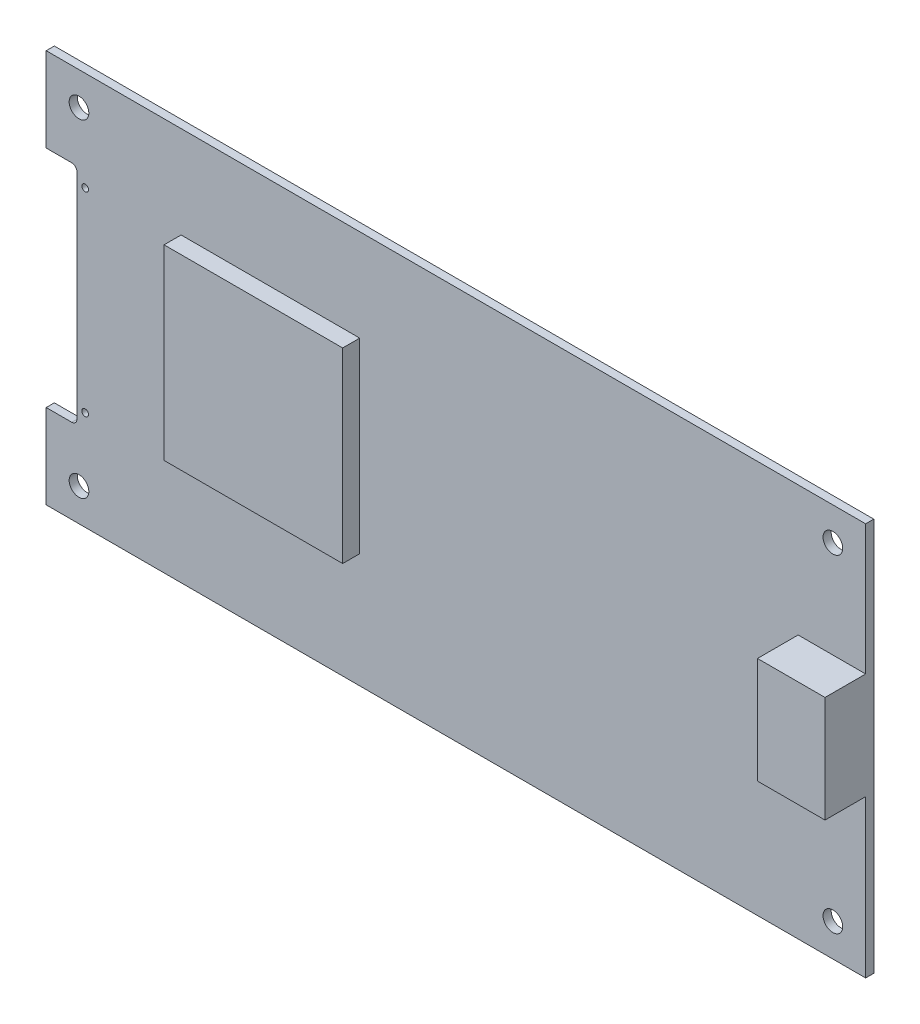
from build123d import *

# Parameters (mm, degrees)
SKETCH1_W          = 158.75
SKETCH1_H          = 76.2
EXTRUDE1_DEPTH     = 1.5748
SKETCH2_R          = 1.905
CUT_EXTRUDE2_DEPTH = 1.5748
SKETCH4_R          = 0.65
CUT_EXTRUDE3_DEPTH = 1.5748
SKETCH5_W          = 34.600619195
SKETCH5_H          = 36.173374613
EXTRUDE2_DEPTH     = 3.302
SKETCH6_W          = 13.081
SKETCH6_H          = 20.574
EXTRUDE3_DEPTH     = 7.874


with BuildPart() as part:
    # Sketch1 → Extrude1 (new body)
    with BuildSketch(Plane.XY):
        with Locations((79.375, -38.1)):
            Rectangle(SKETCH1_W, SKETCH1_H)
    extrude(amount=EXTRUDE1_DEPTH)

    # Sketch2 → Cut-Extrude2 (cut)
    with BuildSketch(Plane.XY.offset(1.5748)):
        with Locations((152.4, -6.35)):
            Circle(SKETCH2_R)
        with Locations((6.35, -6.35)):
            Circle(SKETCH2_R)
        with Locations((152.4, -69.85)):
            Circle(SKETCH2_R)
        with Locations((6.35, -69.85)):
            Circle(SKETCH2_R)
    extrude(amount=-CUT_EXTRUDE2_DEPTH, mode=Mode.SUBTRACT)

    # Sketch4 → Cut-Extrude3 (cut)
    with BuildSketch(Plane.XY.offset(1.5748)):
        with Locations((7.55, -19.234912)):
            Circle(SKETCH4_R)
        with Locations((7.55, -56.965088)):
            Circle(SKETCH4_R)
        with BuildLine():
            Line((0, -16.335006), (4.95, -16.335006))
            ThreePointArc((4.95, -16.335006), (5.657106781, -16.627899219), (5.95, -17.335006))
            Line((5.95, -17.335006), (5.95, -58.865006))
            ThreePointArc((5.95, -58.865006), (5.657106781, -59.572112781), (4.95, -59.865006))
            Line((4.95, -59.865006), (0, -59.865006))
            Line((0, -59.865006), (0, -16.335006))
        make_face()
    extrude(amount=-CUT_EXTRUDE3_DEPTH, mode=Mode.SUBTRACT)

    # Sketch5 → Extrude2 (add)
    with BuildSketch(Plane.XY.offset(1.5748)):
        with Locations((43.434262125, -35.937461301)):
            Rectangle(SKETCH5_W, SKETCH5_H)
    extrude(amount=EXTRUDE2_DEPTH)

    # Sketch6 → Extrude3 (add)
    with BuildSketch(Plane.XY.offset(1.5748)):
        with Locations((152.2095, -35.480182663)):
            Rectangle(SKETCH6_W, SKETCH6_H)
    extrude(amount=EXTRUDE3_DEPTH)


solid = part.part
